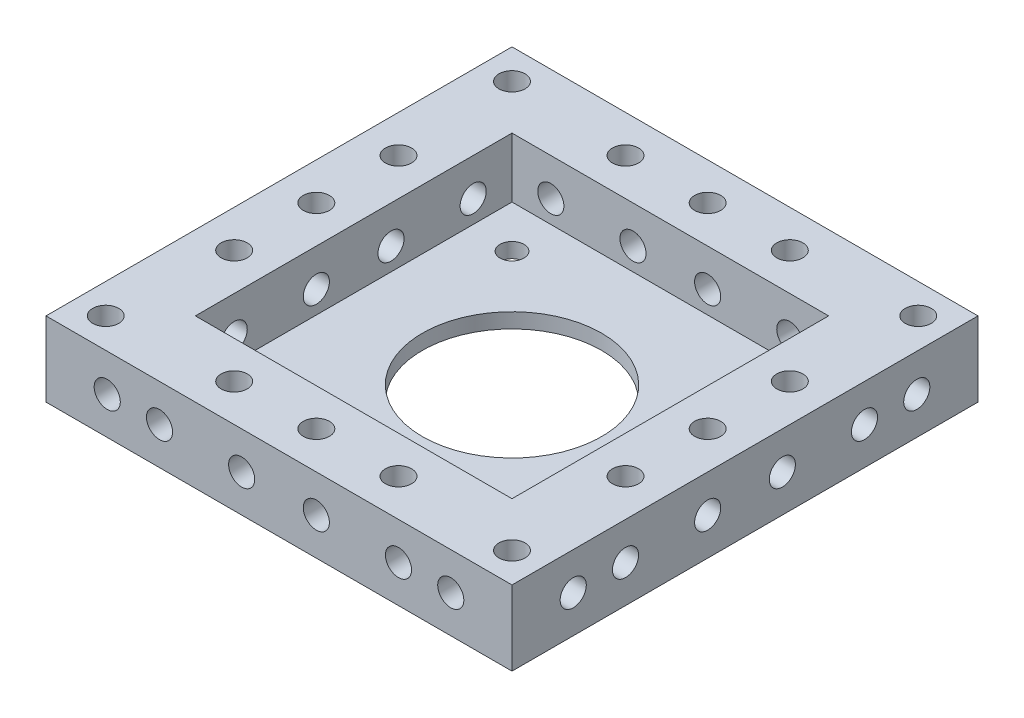
from build123d import *

# Parameters (mm, degrees)
SKETCH_1_W               = 42.4
SKETCH_1_H               = 42.4
EXTRUDE_1_DEPTH          = 2
SKETCH_2_W               = 62.4
SKETCH_2_H               = 62.4
SKETCH_2_W_2             = 42.4
SKETCH_2_H_2             = 42.4
EXTRUDE_2_DEPTH          = 10
CUT_EXTRUDE_1_REACH      = 4
SKETCH_5_R               = 1.6
SKETCH_5_R_2             = 12
CUT_EXTRUDE_START        = -10
SKETCH_7_R               = 1.75
CUT_EXTRUDE_3_DEPTH      = 10
PATTERN_CIRCULAR_2_COUNT = 4
CUT_EXTRUDE_2_REACH      = 12
SKETCH_6_R               = 1.75


with BuildPart() as part:
    # 草图1 → 凸台-拉伸1 (new body)
    with BuildSketch(Plane(origin=(0, 0, 0), x_dir=(1, 0, 0), z_dir=(0, 1, 0))):
        Rectangle(SKETCH_1_W, SKETCH_1_H)
    extrude(amount=EXTRUDE_1_DEPTH)

    # 草图2 → 凸台-拉伸2 (add)
    with BuildSketch(Plane(origin=(0, 0, 0), x_dir=(1, 0, 0), z_dir=(0, 1, 0))):
        Rectangle(SKETCH_2_W, SKETCH_2_H)
        Rectangle(SKETCH_2_W_2, SKETCH_2_H_2, mode=Mode.SUBTRACT)
    extrude(amount=EXTRUDE_2_DEPTH)

    # 草图5 → 切除-拉伸1 (cut, up to next)
    with BuildSketch(Plane(origin=(0, 2, 0), x_dir=(1, 0, 0), z_dir=(0, 1, 0)), mode=Mode.PRIVATE) as cut_extrude_1_sk1:
        with Locations((-15.5, 15.5)):
            Circle(SKETCH_5_R)
    cut_extrude_1_tool1 = extrude(cut_extrude_1_sk1.sketch, amount=-CUT_EXTRUDE_1_REACH, mode=Mode.PRIVATE) & part.part
    add(cut_extrude_1_tool1.solids().sort_by_distance((-15.5, 2, -15.5))[0], mode=Mode.SUBTRACT)
    # 草图5 → 切除-拉伸1 (cut, up to next)
    with BuildSketch(Plane(origin=(0, 2, 0), x_dir=(1, 0, 0), z_dir=(0, 1, 0)), mode=Mode.PRIVATE) as cut_extrude_1_sk2:
        with Locations((15.5, 15.5)):
            Circle(SKETCH_5_R)
    cut_extrude_1_tool2 = extrude(cut_extrude_1_sk2.sketch, amount=-CUT_EXTRUDE_1_REACH, mode=Mode.PRIVATE) & part.part
    add(cut_extrude_1_tool2.solids().sort_by_distance((15.5, 2, -15.5))[0], mode=Mode.SUBTRACT)
    # 草图5 → 切除-拉伸1 (cut, up to next)
    with BuildSketch(Plane(origin=(0, 2, 0), x_dir=(1, 0, 0), z_dir=(0, 1, 0)), mode=Mode.PRIVATE) as cut_extrude_1_sk3:
        with Locations((15.5, -15.5)):
            Circle(SKETCH_5_R)
    cut_extrude_1_tool3 = extrude(cut_extrude_1_sk3.sketch, amount=-CUT_EXTRUDE_1_REACH, mode=Mode.PRIVATE) & part.part
    add(cut_extrude_1_tool3.solids().sort_by_distance((15.5, 2, 15.5))[0], mode=Mode.SUBTRACT)
    # 草图5 → 切除-拉伸1 (cut, up to next)
    with BuildSketch(Plane(origin=(0, 2, 0), x_dir=(1, 0, 0), z_dir=(0, 1, 0)), mode=Mode.PRIVATE) as cut_extrude_1_sk4:
        with Locations((-15.5, -15.5)):
            Circle(SKETCH_5_R)
    cut_extrude_1_tool4 = extrude(cut_extrude_1_sk4.sketch, amount=-CUT_EXTRUDE_1_REACH, mode=Mode.PRIVATE) & part.part
    add(cut_extrude_1_tool4.solids().sort_by_distance((-15.5, 2, 15.5))[0], mode=Mode.SUBTRACT)
    # 草图5 → 切除-拉伸1 (cut, up to next)
    with BuildSketch(Plane(origin=(0, 2, 0), x_dir=(1, 0, 0), z_dir=(0, 1, 0)), mode=Mode.PRIVATE) as cut_extrude_1_sk5:
        Circle(SKETCH_5_R_2)
    cut_extrude_1_tool5 = extrude(cut_extrude_1_sk5.sketch, amount=-CUT_EXTRUDE_1_REACH, mode=Mode.PRIVATE) & part.part
    add(cut_extrude_1_tool5.solids().sort_by_distance((0, 2, 0))[0], mode=Mode.SUBTRACT)

    # 草图7 → 切除-拉伸3 (cut)
    with BuildSketch(Plane.ZY.offset(31.2).offset(CUT_EXTRUDE_START)):
        with Locations((-16, 5)):
            Circle(SKETCH_7_R)
        with Locations((16, 5)):
            Circle(SKETCH_7_R)
        with Locations((-23, 5)):
            Circle(SKETCH_7_R)
        with Locations((23, 5)):
            Circle(SKETCH_7_R)
        with Locations((-5, 5)):
            Circle(SKETCH_7_R)
        with Locations((5, 5)):
            Circle(SKETCH_7_R)
    cut_extrude_3 = extrude(amount=CUT_EXTRUDE_3_DEPTH, mode=Mode.SUBTRACT)

    # 阵列(圆周)2: 切除-拉伸3 ×4 about axis
    pattern_circular_2_axis = Axis((0, 0, 0), (0, 1, 0))
    for i in range(1, PATTERN_CIRCULAR_2_COUNT):
        add(cut_extrude_3.rotate(pattern_circular_2_axis, i * 360 / PATTERN_CIRCULAR_2_COUNT), mode=Mode.SUBTRACT)

    # 草图6 → 切除-拉伸2 (cut, up to next)
    with BuildSketch(Plane(origin=(0, 10, 0), x_dir=(1, 0, 0), z_dir=(0, 1, 0)), mode=Mode.PRIVATE) as cut_extrude_2_sk1:
        with Locations((-27.2, 27.2)):
            Circle(SKETCH_6_R)
    cut_extrude_2_tool1 = extrude(cut_extrude_2_sk1.sketch, amount=-CUT_EXTRUDE_2_REACH, mode=Mode.PRIVATE) & part.part
    add(cut_extrude_2_tool1.solids().sort_by_distance((-27.2, 10, -27.2))[0], mode=Mode.SUBTRACT)
    # 草图6 → 切除-拉伸2 (cut, up to next)
    with BuildSketch(Plane(origin=(0, 10, 0), x_dir=(1, 0, 0), z_dir=(0, 1, 0)), mode=Mode.PRIVATE) as cut_extrude_2_sk2:
        with Locations((-26.2, 11)):
            Circle(SKETCH_6_R)
    cut_extrude_2_tool2 = extrude(cut_extrude_2_sk2.sketch, amount=-CUT_EXTRUDE_2_REACH, mode=Mode.PRIVATE) & part.part
    add(cut_extrude_2_tool2.solids().sort_by_distance((-26.2, 10, -11))[0], mode=Mode.SUBTRACT)
    # 草图6 → 切除-拉伸2 (cut, up to next)
    with BuildSketch(Plane(origin=(0, 10, 0), x_dir=(1, 0, 0), z_dir=(0, 1, 0)), mode=Mode.PRIVATE) as cut_extrude_2_sk3:
        with Locations((-26.2, 0)):
            Circle(SKETCH_6_R)
    cut_extrude_2_tool3 = extrude(cut_extrude_2_sk3.sketch, amount=-CUT_EXTRUDE_2_REACH, mode=Mode.PRIVATE) & part.part
    add(cut_extrude_2_tool3.solids().sort_by_distance((-26.2, 10, 0))[0], mode=Mode.SUBTRACT)
    # 草图6 → 切除-拉伸2 (cut, up to next)
    with BuildSketch(Plane(origin=(0, 10, 0), x_dir=(1, 0, 0), z_dir=(0, 1, 0)), mode=Mode.PRIVATE) as cut_extrude_2_sk4:
        with Locations((-11, 26.2)):
            Circle(SKETCH_6_R)
    cut_extrude_2_tool4 = extrude(cut_extrude_2_sk4.sketch, amount=-CUT_EXTRUDE_2_REACH, mode=Mode.PRIVATE) & part.part
    add(cut_extrude_2_tool4.solids().sort_by_distance((-11, 10, -26.2))[0], mode=Mode.SUBTRACT)
    # 草图6 → 切除-拉伸2 (cut, up to next)
    with BuildSketch(Plane(origin=(0, 10, 0), x_dir=(1, 0, 0), z_dir=(0, 1, 0)), mode=Mode.PRIVATE) as cut_extrude_2_sk5:
        with Locations((0, 26.2)):
            Circle(SKETCH_6_R)
    cut_extrude_2_tool5 = extrude(cut_extrude_2_sk5.sketch, amount=-CUT_EXTRUDE_2_REACH, mode=Mode.PRIVATE) & part.part
    add(cut_extrude_2_tool5.solids().sort_by_distance((0, 10, -26.2))[0], mode=Mode.SUBTRACT)
    # 草图6 → 切除-拉伸2 (cut, up to next)
    with BuildSketch(Plane(origin=(0, 10, 0), x_dir=(1, 0, 0), z_dir=(0, 1, 0)), mode=Mode.PRIVATE) as cut_extrude_2_sk6:
        with Locations((11, 26.2)):
            Circle(SKETCH_6_R)
    cut_extrude_2_tool6 = extrude(cut_extrude_2_sk6.sketch, amount=-CUT_EXTRUDE_2_REACH, mode=Mode.PRIVATE) & part.part
    add(cut_extrude_2_tool6.solids().sort_by_distance((11, 10, -26.2))[0], mode=Mode.SUBTRACT)
    # 草图6 → 切除-拉伸2 (cut, up to next)
    with BuildSketch(Plane(origin=(0, 10, 0), x_dir=(1, 0, 0), z_dir=(0, 1, 0)), mode=Mode.PRIVATE) as cut_extrude_2_sk7:
        with Locations((27.2, 27.2)):
            Circle(SKETCH_6_R)
    cut_extrude_2_tool7 = extrude(cut_extrude_2_sk7.sketch, amount=-CUT_EXTRUDE_2_REACH, mode=Mode.PRIVATE) & part.part
    add(cut_extrude_2_tool7.solids().sort_by_distance((27.2, 10, -27.2))[0], mode=Mode.SUBTRACT)
    # 草图6 → 切除-拉伸2 (cut, up to next)
    with BuildSketch(Plane(origin=(0, 10, 0), x_dir=(1, 0, 0), z_dir=(0, 1, 0)), mode=Mode.PRIVATE) as cut_extrude_2_sk8:
        with Locations((26.2, 11)):
            Circle(SKETCH_6_R)
    cut_extrude_2_tool8 = extrude(cut_extrude_2_sk8.sketch, amount=-CUT_EXTRUDE_2_REACH, mode=Mode.PRIVATE) & part.part
    add(cut_extrude_2_tool8.solids().sort_by_distance((26.2, 10, -11))[0], mode=Mode.SUBTRACT)
    # 草图6 → 切除-拉伸2 (cut, up to next)
    with BuildSketch(Plane(origin=(0, 10, 0), x_dir=(1, 0, 0), z_dir=(0, 1, 0)), mode=Mode.PRIVATE) as cut_extrude_2_sk9:
        with Locations((26.2, 0)):
            Circle(SKETCH_6_R)
    cut_extrude_2_tool9 = extrude(cut_extrude_2_sk9.sketch, amount=-CUT_EXTRUDE_2_REACH, mode=Mode.PRIVATE) & part.part
    add(cut_extrude_2_tool9.solids().sort_by_distance((26.2, 10, 0))[0], mode=Mode.SUBTRACT)
    # 草图6 → 切除-拉伸2 (cut, up to next)
    with BuildSketch(Plane(origin=(0, 10, 0), x_dir=(1, 0, 0), z_dir=(0, 1, 0)), mode=Mode.PRIVATE) as cut_extrude_2_sk10:
        with Locations((26.2, -11)):
            Circle(SKETCH_6_R)
    cut_extrude_2_tool10 = extrude(cut_extrude_2_sk10.sketch, amount=-CUT_EXTRUDE_2_REACH, mode=Mode.PRIVATE) & part.part
    add(cut_extrude_2_tool10.solids().sort_by_distance((26.2, 10, 11))[0], mode=Mode.SUBTRACT)
    # 草图6 → 切除-拉伸2 (cut, up to next)
    with BuildSketch(Plane(origin=(0, 10, 0), x_dir=(1, 0, 0), z_dir=(0, 1, 0)), mode=Mode.PRIVATE) as cut_extrude_2_sk11:
        with Locations((27.2, -27.2)):
            Circle(SKETCH_6_R)
    cut_extrude_2_tool11 = extrude(cut_extrude_2_sk11.sketch, amount=-CUT_EXTRUDE_2_REACH, mode=Mode.PRIVATE) & part.part
    add(cut_extrude_2_tool11.solids().sort_by_distance((27.2, 10, 27.2))[0], mode=Mode.SUBTRACT)
    # 草图6 → 切除-拉伸2 (cut, up to next)
    with BuildSketch(Plane(origin=(0, 10, 0), x_dir=(1, 0, 0), z_dir=(0, 1, 0)), mode=Mode.PRIVATE) as cut_extrude_2_sk12:
        with Locations((11, -26.2)):
            Circle(SKETCH_6_R)
    cut_extrude_2_tool12 = extrude(cut_extrude_2_sk12.sketch, amount=-CUT_EXTRUDE_2_REACH, mode=Mode.PRIVATE) & part.part
    add(cut_extrude_2_tool12.solids().sort_by_distance((11, 10, 26.2))[0], mode=Mode.SUBTRACT)
    # 草图6 → 切除-拉伸2 (cut, up to next)
    with BuildSketch(Plane(origin=(0, 10, 0), x_dir=(1, 0, 0), z_dir=(0, 1, 0)), mode=Mode.PRIVATE) as cut_extrude_2_sk13:
        with Locations((0, -26.2)):
            Circle(SKETCH_6_R)
    cut_extrude_2_tool13 = extrude(cut_extrude_2_sk13.sketch, amount=-CUT_EXTRUDE_2_REACH, mode=Mode.PRIVATE) & part.part
    add(cut_extrude_2_tool13.solids().sort_by_distance((0, 10, 26.2))[0], mode=Mode.SUBTRACT)
    # 草图6 → 切除-拉伸2 (cut, up to next)
    with BuildSketch(Plane(origin=(0, 10, 0), x_dir=(1, 0, 0), z_dir=(0, 1, 0)), mode=Mode.PRIVATE) as cut_extrude_2_sk14:
        with Locations((-11, -26.2)):
            Circle(SKETCH_6_R)
    cut_extrude_2_tool14 = extrude(cut_extrude_2_sk14.sketch, amount=-CUT_EXTRUDE_2_REACH, mode=Mode.PRIVATE) & part.part
    add(cut_extrude_2_tool14.solids().sort_by_distance((-11, 10, 26.2))[0], mode=Mode.SUBTRACT)
    # 草图6 → 切除-拉伸2 (cut, up to next)
    with BuildSketch(Plane(origin=(0, 10, 0), x_dir=(1, 0, 0), z_dir=(0, 1, 0)), mode=Mode.PRIVATE) as cut_extrude_2_sk15:
        with Locations((-27.2, -27.2)):
            Circle(SKETCH_6_R)
    cut_extrude_2_tool15 = extrude(cut_extrude_2_sk15.sketch, amount=-CUT_EXTRUDE_2_REACH, mode=Mode.PRIVATE) & part.part
    add(cut_extrude_2_tool15.solids().sort_by_distance((-27.2, 10, 27.2))[0], mode=Mode.SUBTRACT)
    # 草图6 → 切除-拉伸2 (cut, up to next)
    with BuildSketch(Plane(origin=(0, 10, 0), x_dir=(1, 0, 0), z_dir=(0, 1, 0)), mode=Mode.PRIVATE) as cut_extrude_2_sk16:
        with Locations((-26.2, -11)):
            Circle(SKETCH_6_R)
    cut_extrude_2_tool16 = extrude(cut_extrude_2_sk16.sketch, amount=-CUT_EXTRUDE_2_REACH, mode=Mode.PRIVATE) & part.part
    add(cut_extrude_2_tool16.solids().sort_by_distance((-26.2, 10, 11))[0], mode=Mode.SUBTRACT)


solid = part.part
